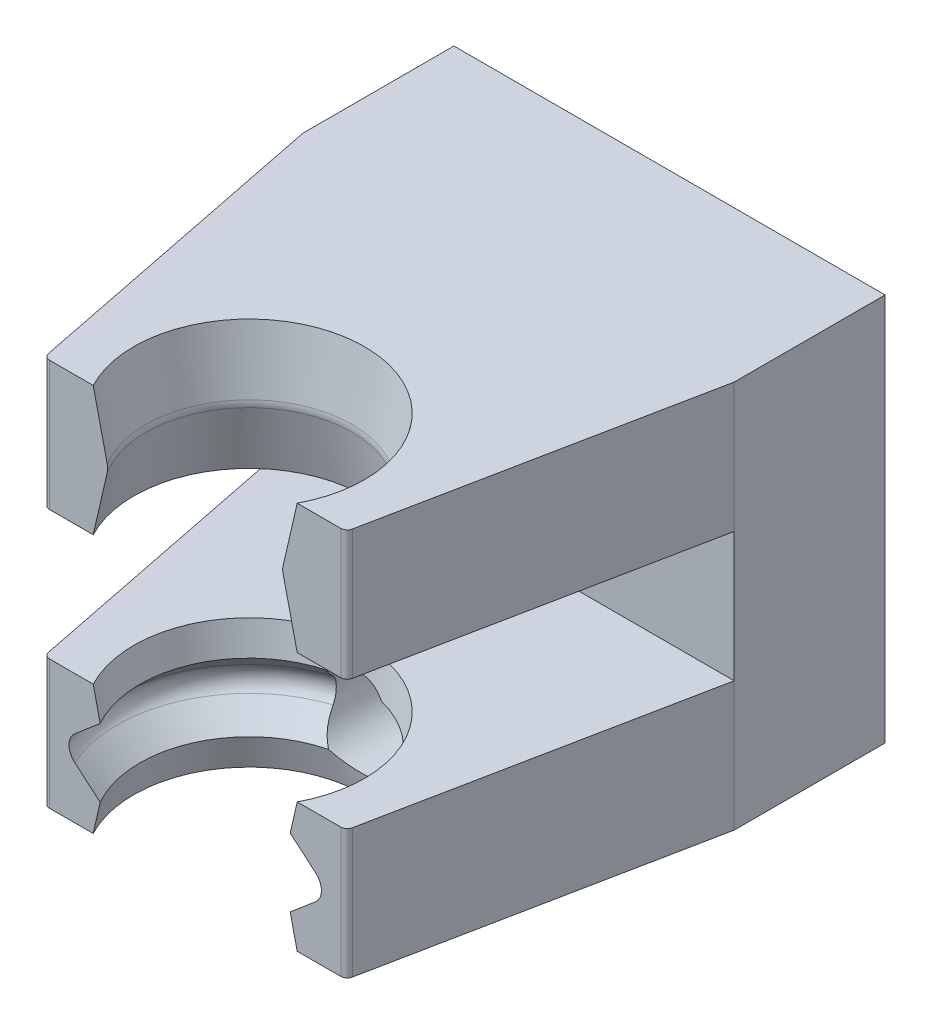
from build123d import *

# Parameters (mm, degrees)
SKETCH1_W               = 20
SKETCH1_H               = 18
BOSS_EXTRUDE1_DEPTH     = 7
SKETCH2_W               = 20
SKETCH2_H               = 6
BOSS_EXTRUDE2_DEPTH     = 15
CUT_EXTRUDE1_REACH      = 32.133
SKETCH3_R               = 5.35
SKETCH5_W               = 14
SKETCH5_H               = 6
CUT_EXTRUDE2_DEPTH      = 26.787593916
FILLET1_R               = 0.3
SKETCH6_W               = 20
SKETCH6_H               = 9
CUT_EXTRUDE3_DEPTH      = 21.149441799
CUT_EXTRUDE3_DEPTH_BACK = 21.149441799
SKETCH7_R               = 2
CUT_EXTRUDE4_DEPTH      = 26.787594037
CUT_EXTRUDE4_DEPTH_BACK = 26.787594037


with BuildPart() as part:
    # Sketch1 → Boss-Extrude1 (new body)
    with BuildSketch(Plane.XY):
        Rectangle(SKETCH1_W, SKETCH1_H)
    extrude(amount=BOSS_EXTRUDE1_DEPTH)

    # Sketch2 → Boss-Extrude2 (add)
    with BuildSketch(Plane.XY.offset(7)):
        with Locations((0, -6)):
            Rectangle(SKETCH2_W, SKETCH2_H)
        with Locations((0, 6)):
            Rectangle(SKETCH2_W, SKETCH2_H)
    extrude(amount=BOSS_EXTRUDE2_DEPTH)

    # Cut-Extrude1: up to this face of the body (flat: up to its plane)
    cut_extrude1_end = Plane(part.part.faces().sort_by_distance((0, 9, 11))[0])
    # Sketch3 → Cut-Extrude1 (cut, up to the picked face)
    with BuildSketch(Plane.XZ.offset(9), mode=Mode.PRIVATE) as cut_extrude1_sk1:
        with Locations((0, 19.5)):
            Circle(SKETCH3_R)
    cut_extrude1_tool1 = split(extrude(cut_extrude1_sk1.sketch, amount=-CUT_EXTRUDE1_REACH, mode=Mode.PRIVATE), bisect_by=cut_extrude1_end, keep=Keep.BOTH, mode=Mode.PRIVATE)
    # Sketch3 → Cut-Extrude1 (cut, up to the picked face)
    with BuildSketch(Plane.XZ.offset(9), mode=Mode.PRIVATE) as cut_extrude1_sk2:
        Polygon((-7, 22), (-10, 7), (-10, 22), align=None)
    cut_extrude1_tool2 = split(extrude(cut_extrude1_sk2.sketch, amount=-CUT_EXTRUDE1_REACH, mode=Mode.PRIVATE), bisect_by=cut_extrude1_end, keep=Keep.BOTH, mode=Mode.PRIVATE)
    # Sketch3 → Cut-Extrude1 (cut, up to the picked face)
    with BuildSketch(Plane.XZ.offset(9), mode=Mode.PRIVATE) as cut_extrude1_sk3:
        Polygon((7, 22), (10, 22), (10, 7), align=None)
    cut_extrude1_tool3 = split(extrude(cut_extrude1_sk3.sketch, amount=-CUT_EXTRUDE1_REACH, mode=Mode.PRIVATE), bisect_by=cut_extrude1_end, keep=Keep.BOTH, mode=Mode.PRIVATE)
    add(cut_extrude1_tool1.solids().sort_by(Axis((0, -9, 19.5), (0, 1, 0)))[0], mode=Mode.SUBTRACT)
    add(cut_extrude1_tool2.solids().sort_by(Axis((-9, -9, 17), (0, 1, 0)))[0], mode=Mode.SUBTRACT)
    add(cut_extrude1_tool3.solids().sort_by(Axis((9, -9, 17), (0, 1, 0)))[0], mode=Mode.SUBTRACT)

    # Sketch4 → Revolve4 (revolve)
    with BuildSketch(Plane.XY.offset(19.5), mode=Mode.PRIVATE) as revolve4_sk:
        with BuildLine():
            Line((-4.781378582, -5.843107092), (-5.35, -3))
            Line((-5.35, -3), (-5.35, -6))
            Line((-5.35, -6), (-4.765843122, -6))
            ThreePointArc((-4.765843122, -6), (-4.769736461, -5.921169906), (-4.781378582, -5.843107092))
        make_face()
        with BuildLine():
            Line((-4.765843122, -6), (-5.35, -6))
            Line((-5.35, -6), (-5.35, -9))
            Line((-5.35, -9), (-4.781378582, -6.156892908))
            ThreePointArc((-4.781378582, -6.156892908), (-4.769736461, -6.078830094), (-4.765843122, -6))
        make_face()
    revolve(revolve4_sk.sketch.rotate(Axis((0, -3, 19.5), (0, -1, 0)), 270), axis=Axis((0, -3, 19.5), (0, -1, 0)))

    # Sketch5 → Cut-Extrude2 (cut, through all)
    with BuildSketch(Plane.XY.offset(22)):
        with Locations((0, -6)):
            Rectangle(SKETCH5_W, SKETCH5_H)
    extrude(amount=CUT_EXTRUDE2_DEPTH, mode=Mode.SUBTRACT)

    # Fillet1
    fillet1_edges = [part.edges().sort_by_distance(p)[0] for p in [
        (7, -6, 22),
        (-7, -6, 22),
        (-7, 6, 22),
        (7, 6, 22),
        (-4.729957717, 6, 22),
        (4.729957717, 6, 22),
    ]]
    fillet(fillet1_edges, radius=FILLET1_R)

    # Sketch6 → Cut-Extrude3 (cut, two sides)
    with BuildSketch(Plane.XY.offset(7)) as cut_extrude3_sk:
        with Locations((0, 4.5)):
            Rectangle(SKETCH6_W, SKETCH6_H)
    extrude(amount=CUT_EXTRUDE3_DEPTH, mode=Mode.SUBTRACT)
    extrude(cut_extrude3_sk.sketch, amount=-CUT_EXTRUDE3_DEPTH_BACK, mode=Mode.SUBTRACT)

    # Mirror2: part across plane


with BuildPart() as part_1:
    add(part.part)
    add(part.part.mirror(Plane(origin=(-10, 0, 0), x_dir=(0, 0, 1), z_dir=(0, -1, 0))))

    # Sketch7 → Cut-Extrude4 (cut, two sides)
    with BuildSketch(Plane(origin=(0, 0, 0), x_dir=(-1, 0, 0), z_dir=(0, 0, -1))) as cut_extrude4_sk:
        with Locations((0, -6)):
            Circle(SKETCH7_R)
    extrude(amount=CUT_EXTRUDE4_DEPTH, mode=Mode.SUBTRACT)
    extrude(cut_extrude4_sk.sketch, amount=-CUT_EXTRUDE4_DEPTH_BACK, mode=Mode.SUBTRACT)

    # Sketch8 → Cut-Revolve1 (revolve, cut)
    with BuildSketch(Plane.XY.offset(19.5)):
        with BuildLine():
            Line((-6.116799524, -6.580040554), (-5.065689291, -7.578446454))
            Line((-5.065689291, -7.578446454), (-4.781378582, -6.156892908))
            ThreePointArc((-4.781378582, -6.156892908), (-4.765843122, -6), (-4.781378582, -5.843107092))
            Line((-4.781378582, -5.843107092), (-5.065689291, -4.421553546))
            Line((-5.065689291, -4.421553546), (-6.116799524, -5.419959446))
            ThreePointArc((-6.116799524, -5.419959446), (-6.365843122, -6), (-6.116799524, -6.580040554))
        make_face()
    revolve(axis=Axis((0, -3, 19.5), (0, -1, 0)), mode=Mode.SUBTRACT)


solid = part_1.part
